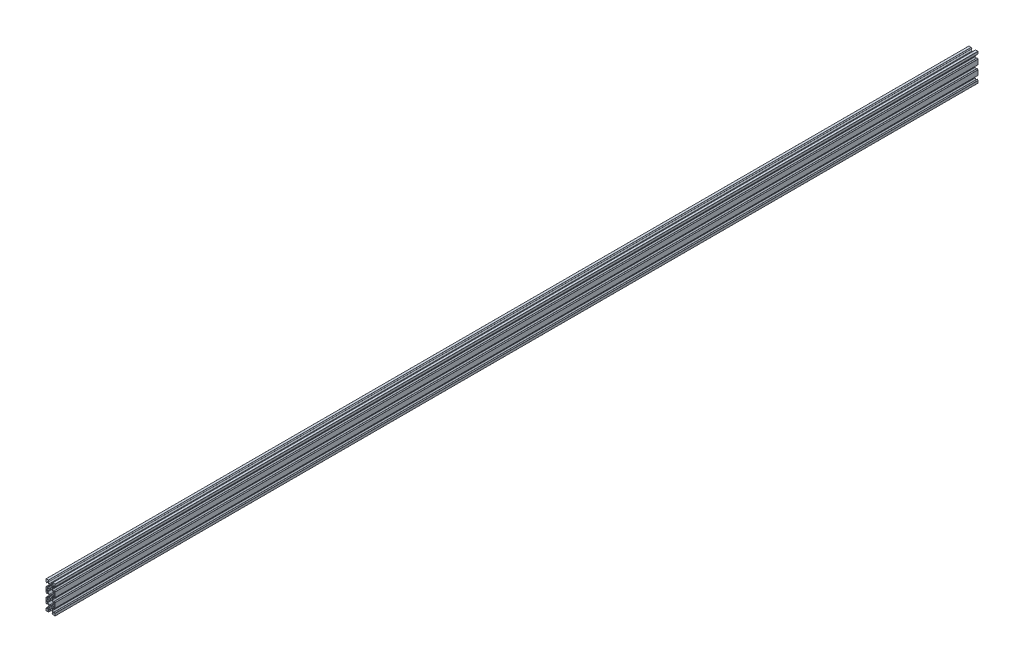
from build123d import *

# Parameters (mm, degrees)
BOSS_EXTRU_1_DEPTH = 2000


with BuildPart() as part:
    # Esquisse1 → Boss.-Extru.1 (new body)
    with BuildSketch(Plane.XY):
        with BuildLine():
            Line((6.114160649, 19.573320158), (6.414160649, 20.0929354))
            Line((6.414160649, 20.0929354), (6.414160649, 22.289056089))
            ThreePointArc((6.414160649, 22.289056089), (6.43699679, 22.403861119), (6.502028615, 22.501188124))
            Line((6.502028615, 22.501188124), (8.985632512, 24.984792021))
            ThreePointArc((8.985632512, 24.984792021), (9.082959517, 25.049823846), (9.197764546, 25.072659986))
            Line((9.197764546, 25.072659986), (10.413500478, 25.072659986))
            ThreePointArc((10.413500478, 25.072659986), (10.625632512, 24.984792021), (10.713500478, 24.772659986))
            Line((10.713500478, 24.772659986), (10.713500478, 22.773320158))
            ThreePointArc((10.713500478, 22.773320158), (10.775232134, 22.680932205), (10.884211156, 22.70260948))
            Line((10.884211156, 22.70260948), (12.425632512, 24.244030836))
            ThreePointArc((12.425632512, 24.244030836), (12.490664337, 24.341357841), (12.513500478, 24.456162871))
            Line((12.513500478, 24.456162871), (12.513500478, 29.273320158))
            ThreePointArc((12.513500478, 29.273320158), (12.425632512, 29.485452192), (12.213500478, 29.573320158))
            Line((12.213500478, 29.573320158), (7.39634319, 29.573320158))
            ThreePointArc((7.39634319, 29.573320158), (7.28153816, 29.550484018), (7.184211156, 29.485452192))
            Line((7.184211156, 29.485452192), (5.642789799, 27.944030836))
            ThreePointArc((5.642789799, 27.944030836), (5.621112524, 27.835051815), (5.713500478, 27.773320158))
            Line((5.713500478, 27.773320158), (7.712840306, 27.773320158))
            ThreePointArc((7.712840306, 27.773320158), (7.92497234, 27.685452192), (8.012840306, 27.473320158))
            Line((8.012840306, 27.473320158), (8.012840306, 26.257584227))
            ThreePointArc((8.012840306, 26.257584227), (7.990004166, 26.142779197), (7.92497234, 26.045452192))
            Line((7.92497234, 26.045452192), (5.441368443, 23.561848296))
            ThreePointArc((5.441368443, 23.561848296), (5.344041439, 23.49681647), (5.229236409, 23.47398033))
            Line((5.229236409, 23.47398033), (3.03311572, 23.47398033))
            Line((3.03311572, 23.47398033), (2.513500478, 23.17398033))
            Line((2.513500478, 23.17398033), (1.993885235, 23.47398033))
            Line((1.993885235, 23.47398033), (-0.202235454, 23.47398033))
            ThreePointArc((-0.202235454, 23.47398033), (-0.317040483, 23.49681647), (-0.414367488, 23.561848296))
            Line((-0.414367488, 23.561848296), (-2.897971385, 26.045452192))
            ThreePointArc((-2.897971385, 26.045452192), (-2.96300321, 26.142779197), (-2.985839351, 26.257584227))
            Line((-2.985839351, 26.257584227), (-2.985839351, 27.473320158))
            ThreePointArc((-2.985839351, 27.473320158), (-2.897971385, 27.685452192), (-2.685839351, 27.773320158))
            Line((-2.685839351, 27.773320158), (-0.686499522, 27.773320158))
            ThreePointArc((-0.686499522, 27.773320158), (-0.594111569, 27.835051815), (-0.615788844, 27.944030836))
            Line((-0.615788844, 27.944030836), (-2.157210201, 29.485452192))
            ThreePointArc((-2.157210201, 29.485452192), (-2.254537205, 29.550484018), (-2.369342235, 29.573320158))
            Line((-2.369342235, 29.573320158), (-7.186499522, 29.573320158))
            ThreePointArc((-7.186499522, 29.573320158), (-7.398631557, 29.485452192), (-7.486499522, 29.273320158))
            Line((-7.486499522, 29.273320158), (-7.486499522, 24.456162871))
            ThreePointArc((-7.486499522, 24.456162871), (-7.463663382, 24.341357841), (-7.398631557, 24.244030836))
            Line((-7.398631557, 24.244030836), (-5.857210201, 22.70260948))
            ThreePointArc((-5.857210201, 22.70260948), (-5.748231179, 22.680932205), (-5.686499522, 22.773320158))
            Line((-5.686499522, 22.773320158), (-5.686499522, 24.772659986))
            ThreePointArc((-5.686499522, 24.772659986), (-5.598631557, 24.984792021), (-5.386499522, 25.072659986))
            Line((-5.386499522, 25.072659986), (-4.170763591, 25.072659986))
            ThreePointArc((-4.170763591, 25.072659986), (-4.055958561, 25.049823846), (-3.958631557, 24.984792021))
            Line((-3.958631557, 24.984792021), (-1.47502766, 22.501188124))
            ThreePointArc((-1.47502766, 22.501188124), (-1.409995834, 22.403861119), (-1.387159694, 22.289056089))
            Line((-1.387159694, 22.289056089), (-1.387159694, 20.0929354))
            Line((-1.387159694, 20.0929354), (-1.087159694, 19.573320158))
            Line((-1.087159694, 19.573320158), (-1.387159694, 19.053704916))
            Line((-1.387159694, 19.053704916), (-1.387159694, 16.857584227))
            ThreePointArc((-1.387159694, 16.857584227), (-1.409995834, 16.742779197), (-1.47502766, 16.645452192))
            Line((-1.47502766, 16.645452192), (-3.958631557, 14.161848296))
            ThreePointArc((-3.958631557, 14.161848296), (-4.055958561, 14.09681647), (-4.170763591, 14.07398033))
            Line((-4.170763591, 14.07398033), (-5.386499522, 14.07398033))
            ThreePointArc((-5.386499522, 14.07398033), (-5.598631557, 14.161848296), (-5.686499522, 14.37398033))
            Line((-5.686499522, 14.37398033), (-5.686499522, 16.373320158))
            ThreePointArc((-5.686499522, 16.373320158), (-5.748231179, 16.465708111), (-5.857210201, 16.444030836))
            Line((-5.857210201, 16.444030836), (-7.398631557, 14.90260948))
            ThreePointArc((-7.398631557, 14.90260948), (-7.463663382, 14.805282475), (-7.486499522, 14.690477446))
            Line((-7.486499522, 14.690477446), (-7.486499522, 9.573320158))
            Line((-7.486499522, 9.573320158), (-7.486499522, 4.456162871))
            ThreePointArc((-7.486499522, 4.456162871), (-7.463663382, 4.341357841), (-7.398631557, 4.244030836))
            Line((-7.398631557, 4.244030836), (-5.857210201, 2.70260948))
            ThreePointArc((-5.857210201, 2.70260948), (-5.748231179, 2.680932205), (-5.686499522, 2.773320158))
            Line((-5.686499522, 2.773320158), (-5.686499522, 4.772659986))
            ThreePointArc((-5.686499522, 4.772659986), (-5.598631557, 4.984792021), (-5.386499522, 5.072659986))
            Line((-5.386499522, 5.072659986), (-4.170763591, 5.072659986))
            ThreePointArc((-4.170763591, 5.072659986), (-4.055958561, 5.049823846), (-3.958631557, 4.984792021))
            Line((-3.958631557, 4.984792021), (-1.47502766, 2.501188124))
            ThreePointArc((-1.47502766, 2.501188124), (-1.409995834, 2.403861119), (-1.387159694, 2.289056089))
            Line((-1.387159694, 2.289056089), (-1.387159694, 0.0929354))
            Line((-1.387159694, 0.0929354), (-1.087159694, -0.426679842))
            Line((-1.087159694, -0.426679842), (-1.387159694, -0.946295084))
            Line((-1.387159694, -0.946295084), (-1.387159694, -3.142415773))
            ThreePointArc((-1.387159694, -3.142415773), (-1.409995834, -3.257220803), (-1.47502766, -3.354547808))
            Line((-1.47502766, -3.354547808), (-3.958631557, -5.838151704))
            ThreePointArc((-3.958631557, -5.838151704), (-4.055958561, -5.90318353), (-4.170763591, -5.92601967))
            Line((-4.170763591, -5.92601967), (-5.386499522, -5.92601967))
            ThreePointArc((-5.386499522, -5.92601967), (-5.598631557, -5.838151704), (-5.686499522, -5.62601967))
            Line((-5.686499522, -5.62601967), (-5.686499522, -3.626679842))
            ThreePointArc((-5.686499522, -3.626679842), (-5.748231179, -3.534291889), (-5.857210201, -3.555969164))
            Line((-5.857210201, -3.555969164), (-7.398631557, -5.09739052))
            ThreePointArc((-7.398631557, -5.09739052), (-7.463663382, -5.194717525), (-7.486499522, -5.309522554))
            Line((-7.486499522, -5.309522554), (-7.486499522, -10.426679842))
            Line((-7.486499522, -10.426679842), (-7.486499522, -15.543837129))
            ThreePointArc((-7.486499522, -15.543837129), (-7.463663382, -15.658642159), (-7.398631557, -15.755969164))
            Line((-7.398631557, -15.755969164), (-5.857210201, -17.29739052))
            ThreePointArc((-5.857210201, -17.29739052), (-5.748231179, -17.319067795), (-5.686499522, -17.226679842))
            Line((-5.686499522, -17.226679842), (-5.686499522, -15.227340014))
            ThreePointArc((-5.686499522, -15.227340014), (-5.598631557, -15.015207979), (-5.386499522, -14.927340014))
            Line((-5.386499522, -14.927340014), (-4.170763591, -14.927340014))
            ThreePointArc((-4.170763591, -14.927340014), (-4.055958561, -14.950176154), (-3.958631557, -15.015207979))
            Line((-3.958631557, -15.015207979), (-1.47502766, -17.498811876))
            ThreePointArc((-1.47502766, -17.498811876), (-1.409995834, -17.596138881), (-1.387159694, -17.710943911))
            Line((-1.387159694, -17.710943911), (-1.387159694, -19.9070646))
            Line((-1.387159694, -19.9070646), (-1.087159694, -20.426679842))
            Line((-1.087159694, -20.426679842), (-1.387159694, -20.946295084))
            Line((-1.387159694, -20.946295084), (-1.387159694, -23.142415773))
            ThreePointArc((-1.387159694, -23.142415773), (-1.409995834, -23.257220803), (-1.47502766, -23.354547808))
            Line((-1.47502766, -23.354547808), (-3.958631557, -25.838151704))
            ThreePointArc((-3.958631557, -25.838151704), (-4.055958561, -25.90318353), (-4.170763591, -25.92601967))
            Line((-4.170763591, -25.92601967), (-5.386499522, -25.92601967))
            ThreePointArc((-5.386499522, -25.92601967), (-5.598631557, -25.838151704), (-5.686499522, -25.62601967))
            Line((-5.686499522, -25.62601967), (-5.686499522, -23.626679842))
            ThreePointArc((-5.686499522, -23.626679842), (-5.748231179, -23.534291889), (-5.857210201, -23.555969164))
            Line((-5.857210201, -23.555969164), (-7.398631557, -25.09739052))
            ThreePointArc((-7.398631557, -25.09739052), (-7.463663382, -25.194717525), (-7.486499522, -25.309522554))
            Line((-7.486499522, -25.309522554), (-7.486499522, -30.126679842))
            ThreePointArc((-7.486499522, -30.126679842), (-7.398631557, -30.338811876), (-7.186499522, -30.426679842))
            Line((-7.186499522, -30.426679842), (-2.369342235, -30.426679842))
            ThreePointArc((-2.369342235, -30.426679842), (-2.254537205, -30.403843702), (-2.157210201, -30.338811876))
            Line((-2.157210201, -30.338811876), (-0.615788844, -28.79739052))
            ThreePointArc((-0.615788844, -28.79739052), (-0.594111569, -28.688411499), (-0.686499522, -28.626679842))
            Line((-0.686499522, -28.626679842), (-2.685839351, -28.626679842))
            ThreePointArc((-2.685839351, -28.626679842), (-2.897971385, -28.538811876), (-2.985839351, -28.326679842))
            Line((-2.985839351, -28.326679842), (-2.985839351, -27.110943911))
            ThreePointArc((-2.985839351, -27.110943911), (-2.96300321, -26.996138881), (-2.897971385, -26.898811876))
            Line((-2.897971385, -26.898811876), (-0.414367488, -24.415207979))
            ThreePointArc((-0.414367488, -24.415207979), (-0.317040483, -24.350176154), (-0.202235454, -24.327340014))
            Line((-0.202235454, -24.327340014), (1.993885235, -24.327340014))
            Line((1.993885235, -24.327340014), (2.513500478, -24.027340014))
            Line((2.513500478, -24.027340014), (3.03311572, -24.327340014))
            Line((3.03311572, -24.327340014), (5.229236409, -24.327340014))
            ThreePointArc((5.229236409, -24.327340014), (5.344041439, -24.350176154), (5.441368443, -24.415207979))
            Line((5.441368443, -24.415207979), (7.92497234, -26.898811876))
            ThreePointArc((7.92497234, -26.898811876), (7.990004166, -26.996138881), (8.012840306, -27.110943911))
            Line((8.012840306, -27.110943911), (8.012840306, -28.326679842))
            ThreePointArc((8.012840306, -28.326679842), (7.92497234, -28.538811876), (7.712840306, -28.626679842))
            Line((7.712840306, -28.626679842), (5.713500478, -28.626679842))
            ThreePointArc((5.713500478, -28.626679842), (5.621112524, -28.688411499), (5.642789799, -28.79739052))
            Line((5.642789799, -28.79739052), (7.184211156, -30.338811876))
            ThreePointArc((7.184211156, -30.338811876), (7.28153816, -30.403843702), (7.39634319, -30.426679842))
            Line((7.39634319, -30.426679842), (12.213500478, -30.426679842))
            ThreePointArc((12.213500478, -30.426679842), (12.425632512, -30.338811876), (12.513500478, -30.126679842))
            Line((12.513500478, -30.126679842), (12.513500478, -25.309522554))
            ThreePointArc((12.513500478, -25.309522554), (12.490664337, -25.194717525), (12.425632512, -25.09739052))
            Line((12.425632512, -25.09739052), (10.884211156, -23.555969164))
            ThreePointArc((10.884211156, -23.555969164), (10.775232134, -23.534291889), (10.713500478, -23.626679842))
            Line((10.713500478, -23.626679842), (10.713500478, -25.62601967))
            ThreePointArc((10.713500478, -25.62601967), (10.625632512, -25.838151704), (10.413500478, -25.92601967))
            Line((10.413500478, -25.92601967), (9.197764546, -25.92601967))
            ThreePointArc((9.197764546, -25.92601967), (9.082959517, -25.90318353), (8.985632512, -25.838151704))
            Line((8.985632512, -25.838151704), (6.502028615, -23.354547808))
            ThreePointArc((6.502028615, -23.354547808), (6.43699679, -23.257220803), (6.414160649, -23.142415773))
            Line((6.414160649, -23.142415773), (6.414160649, -20.946295084))
            Line((6.414160649, -20.946295084), (6.114160649, -20.426679842))
            Line((6.114160649, -20.426679842), (6.414160649, -19.9070646))
            Line((6.414160649, -19.9070646), (6.414160649, -17.710943911))
            ThreePointArc((6.414160649, -17.710943911), (6.43699679, -17.596138881), (6.502028615, -17.498811876))
            Line((6.502028615, -17.498811876), (8.985632512, -15.015207979))
            ThreePointArc((8.985632512, -15.015207979), (9.082959517, -14.950176154), (9.197764546, -14.927340014))
            Line((9.197764546, -14.927340014), (10.413500478, -14.927340014))
            ThreePointArc((10.413500478, -14.927340014), (10.625632512, -15.015207979), (10.713500478, -15.227340014))
            Line((10.713500478, -15.227340014), (10.713500478, -17.226679842))
            ThreePointArc((10.713500478, -17.226679842), (10.775232134, -17.319067795), (10.884211156, -17.29739052))
            Line((10.884211156, -17.29739052), (12.425632512, -15.755969164))
            ThreePointArc((12.425632512, -15.755969164), (12.490664337, -15.658642159), (12.513500478, -15.543837129))
            Line((12.513500478, -15.543837129), (12.513500478, -10.426679842))
            Line((12.513500478, -10.426679842), (12.513500478, -5.309522554))
            ThreePointArc((12.513500478, -5.309522554), (12.490664337, -5.194717525), (12.425632512, -5.09739052))
            Line((12.425632512, -5.09739052), (10.884211156, -3.555969164))
            ThreePointArc((10.884211156, -3.555969164), (10.775232134, -3.534291889), (10.713500478, -3.626679842))
            Line((10.713500478, -3.626679842), (10.713500478, -5.62601967))
            ThreePointArc((10.713500478, -5.62601967), (10.625632512, -5.838151704), (10.413500478, -5.92601967))
            Line((10.413500478, -5.92601967), (9.197764546, -5.92601967))
            ThreePointArc((9.197764546, -5.92601967), (9.082959517, -5.90318353), (8.985632512, -5.838151704))
            Line((8.985632512, -5.838151704), (6.502028615, -3.354547808))
            ThreePointArc((6.502028615, -3.354547808), (6.43699679, -3.257220803), (6.414160649, -3.142415773))
            Line((6.414160649, -3.142415773), (6.414160649, -0.946295084))
            Line((6.414160649, -0.946295084), (6.114160649, -0.426679842))
            Line((6.114160649, -0.426679842), (6.414160649, 0.0929354))
            Line((6.414160649, 0.0929354), (6.414160649, 2.289056089))
            ThreePointArc((6.414160649, 2.289056089), (6.43699679, 2.403861119), (6.502028615, 2.501188124))
            Line((6.502028615, 2.501188124), (8.985632512, 4.984792021))
            ThreePointArc((8.985632512, 4.984792021), (9.082959517, 5.049823846), (9.197764546, 5.072659986))
            Line((9.197764546, 5.072659986), (10.413500478, 5.072659986))
            ThreePointArc((10.413500478, 5.072659986), (10.625632512, 4.984792021), (10.713500478, 4.772659986))
            Line((10.713500478, 4.772659986), (10.713500478, 2.773320158))
            ThreePointArc((10.713500478, 2.773320158), (10.775232134, 2.680932205), (10.884211156, 2.70260948))
            Line((10.884211156, 2.70260948), (12.425632512, 4.244030836))
            ThreePointArc((12.425632512, 4.244030836), (12.490664337, 4.341357841), (12.513500478, 4.456162871))
            Line((12.513500478, 4.456162871), (12.513500478, 9.573320158))
            Line((12.513500478, 9.573320158), (12.513500478, 14.690477446))
            ThreePointArc((12.513500478, 14.690477446), (12.490664337, 14.805282475), (12.425632512, 14.90260948))
            Line((12.425632512, 14.90260948), (10.884211156, 16.444030836))
            ThreePointArc((10.884211156, 16.444030836), (10.775232134, 16.465708111), (10.713500478, 16.373320158))
            Line((10.713500478, 16.373320158), (10.713500478, 14.37398033))
            ThreePointArc((10.713500478, 14.37398033), (10.625632512, 14.161848296), (10.413500478, 14.07398033))
            Line((10.413500478, 14.07398033), (9.197764546, 14.07398033))
            ThreePointArc((9.197764546, 14.07398033), (9.082959517, 14.09681647), (8.985632512, 14.161848296))
            Line((8.985632512, 14.161848296), (6.502028615, 16.645452192))
            ThreePointArc((6.502028615, 16.645452192), (6.43699679, 16.742779197), (6.414160649, 16.857584227))
            Line((6.414160649, 16.857584227), (6.414160649, 19.053704916))
            Line((6.414160649, 19.053704916), (6.114160649, 19.573320158))
        make_face()
        with BuildLine():
            Line((10.413500478, -7.687340014), (8.837764546, -7.687340014))
            ThreePointArc((8.837764546, -7.687340014), (8.722959517, -7.664503873), (8.625632512, -7.599472048))
            Line((8.625632512, -7.599472048), (5.441368443, -4.415207979))
            ThreePointArc((5.441368443, -4.415207979), (5.344041439, -4.350176154), (5.229236409, -4.327340014))
            Line((5.229236409, -4.327340014), (3.03311572, -4.327340014))
            Line((3.03311572, -4.327340014), (2.513500478, -4.027340014))
            Line((2.513500478, -4.027340014), (1.993885235, -4.327340014))
            Line((1.993885235, -4.327340014), (-0.202235454, -4.327340014))
            ThreePointArc((-0.202235454, -4.327340014), (-0.317040483, -4.350176154), (-0.414367488, -4.415207979))
            Line((-0.414367488, -4.415207979), (-3.598631557, -7.599472048))
            ThreePointArc((-3.598631557, -7.599472048), (-3.695958561, -7.664503873), (-3.810763591, -7.687340014))
            Line((-3.810763591, -7.687340014), (-5.386499522, -7.687340014))
            ThreePointArc((-5.386499522, -7.687340014), (-5.598631557, -7.775207979), (-5.686499522, -7.987340014))
            Line((-5.686499522, -7.987340014), (-5.686499522, -10.426679842))
            Line((-5.686499522, -10.426679842), (-5.686499522, -12.86601967))
            ThreePointArc((-5.686499522, -12.86601967), (-5.598631557, -13.078151704), (-5.386499522, -13.16601967))
            Line((-5.386499522, -13.16601967), (-3.810763591, -13.16601967))
            ThreePointArc((-3.810763591, -13.16601967), (-3.695958561, -13.18885581), (-3.598631557, -13.253887636))
            Line((-3.598631557, -13.253887636), (-0.414367488, -16.438151704))
            ThreePointArc((-0.414367488, -16.438151704), (-0.317040483, -16.50318353), (-0.202235454, -16.52601967))
            Line((-0.202235454, -16.52601967), (1.993885235, -16.52601967))
            Line((1.993885235, -16.52601967), (2.513500478, -16.82601967))
            Line((2.513500478, -16.82601967), (3.03311572, -16.52601967))
            Line((3.03311572, -16.52601967), (5.229236409, -16.52601967))
            ThreePointArc((5.229236409, -16.52601967), (5.344041439, -16.50318353), (5.441368443, -16.438151704))
            Line((5.441368443, -16.438151704), (8.625632512, -13.253887636))
            ThreePointArc((8.625632512, -13.253887636), (8.722959517, -13.18885581), (8.837764546, -13.16601967))
            Line((8.837764546, -13.16601967), (10.413500478, -13.16601967))
            ThreePointArc((10.413500478, -13.16601967), (10.625632512, -13.078151704), (10.713500478, -12.86601967))
            Line((10.713500478, -12.86601967), (10.713500478, -10.426679842))
            Line((10.713500478, -10.426679842), (10.713500478, -7.987340014))
            ThreePointArc((10.713500478, -7.987340014), (10.625632512, -7.775207979), (10.413500478, -7.687340014))
        make_face(mode=Mode.SUBTRACT)
        with BuildLine():
            Line((10.413500478, 12.312659986), (8.837764546, 12.312659986))
            ThreePointArc((8.837764546, 12.312659986), (8.722959517, 12.335496127), (8.625632512, 12.400527952))
            Line((8.625632512, 12.400527952), (5.441368443, 15.584792021))
            ThreePointArc((5.441368443, 15.584792021), (5.344041439, 15.649823846), (5.229236409, 15.672659986))
            Line((5.229236409, 15.672659986), (3.03311572, 15.672659986))
            Line((3.03311572, 15.672659986), (2.513500478, 15.972659986))
            Line((2.513500478, 15.972659986), (1.993885235, 15.672659986))
            Line((1.993885235, 15.672659986), (-0.202235454, 15.672659986))
            ThreePointArc((-0.202235454, 15.672659986), (-0.317040483, 15.649823846), (-0.414367488, 15.584792021))
            Line((-0.414367488, 15.584792021), (-3.598631557, 12.400527952))
            ThreePointArc((-3.598631557, 12.400527952), (-3.695958561, 12.335496127), (-3.810763591, 12.312659986))
            Line((-3.810763591, 12.312659986), (-5.386499522, 12.312659986))
            ThreePointArc((-5.386499522, 12.312659986), (-5.598631557, 12.224792021), (-5.686499522, 12.012659986))
            Line((-5.686499522, 12.012659986), (-5.686499522, 9.573320158))
            Line((-5.686499522, 9.573320158), (-5.686499522, 7.13398033))
            ThreePointArc((-5.686499522, 7.13398033), (-5.598631557, 6.921848296), (-5.386499522, 6.83398033))
            Line((-5.386499522, 6.83398033), (-3.810763591, 6.83398033))
            ThreePointArc((-3.810763591, 6.83398033), (-3.695958561, 6.81114419), (-3.598631557, 6.746112364))
            Line((-3.598631557, 6.746112364), (-0.414367488, 3.561848296))
            ThreePointArc((-0.414367488, 3.561848296), (-0.317040483, 3.49681647), (-0.202235454, 3.47398033))
            Line((-0.202235454, 3.47398033), (1.993885235, 3.47398033))
            Line((1.993885235, 3.47398033), (2.513500478, 3.17398033))
            Line((2.513500478, 3.17398033), (3.03311572, 3.47398033))
            Line((3.03311572, 3.47398033), (5.229236409, 3.47398033))
            ThreePointArc((5.229236409, 3.47398033), (5.344041439, 3.49681647), (5.441368443, 3.561848296))
            Line((5.441368443, 3.561848296), (8.625632512, 6.746112364))
            ThreePointArc((8.625632512, 6.746112364), (8.722959517, 6.81114419), (8.837764546, 6.83398033))
            Line((8.837764546, 6.83398033), (10.413500478, 6.83398033))
            ThreePointArc((10.413500478, 6.83398033), (10.625632512, 6.921848296), (10.713500478, 7.13398033))
            Line((10.713500478, 7.13398033), (10.713500478, 9.573320158))
            Line((10.713500478, 9.573320158), (10.713500478, 12.012659986))
            ThreePointArc((10.713500478, 12.012659986), (10.625632512, 12.224792021), (10.413500478, 12.312659986))
        make_face(mode=Mode.SUBTRACT)
        with BuildLine():
            ThreePointArc((0.413500478, -20.426679842), (1.028576237, -21.911604082), (2.513500478, -22.526679842))
            ThreePointArc((2.513500478, -22.526679842), (3.998424718, -21.911604082), (4.613500478, -20.426679842))
            ThreePointArc((4.613500478, -20.426679842), (3.998424718, -18.941755601), (2.513500478, -18.326679842))
            ThreePointArc((2.513500478, -18.326679842), (1.028576237, -18.941755601), (0.413500478, -20.426679842))
        make_face(mode=Mode.SUBTRACT)
        with BuildLine():
            ThreePointArc((0.413500478, -0.426679842), (1.028576237, -1.911604082), (2.513500478, -2.526679842))
            ThreePointArc((2.513500478, -2.526679842), (3.998424718, -1.911604082), (4.613500478, -0.426679842))
            ThreePointArc((4.613500478, -0.426679842), (3.998424718, 1.058244399), (2.513500478, 1.673320158))
            ThreePointArc((2.513500478, 1.673320158), (1.028576237, 1.058244399), (0.413500478, -0.426679842))
        make_face(mode=Mode.SUBTRACT)
        with BuildLine():
            ThreePointArc((0.413500478, 19.573320158), (1.028576237, 18.088395918), (2.513500478, 17.473320158))
            ThreePointArc((2.513500478, 17.473320158), (3.998424718, 18.088395918), (4.613500478, 19.573320158))
            ThreePointArc((4.613500478, 19.573320158), (3.998424718, 21.058244399), (2.513500478, 21.673320158))
            ThreePointArc((2.513500478, 21.673320158), (1.028576237, 21.058244399), (0.413500478, 19.573320158))
        make_face(mode=Mode.SUBTRACT)
    extrude(amount=BOSS_EXTRU_1_DEPTH)


solid = part.part
